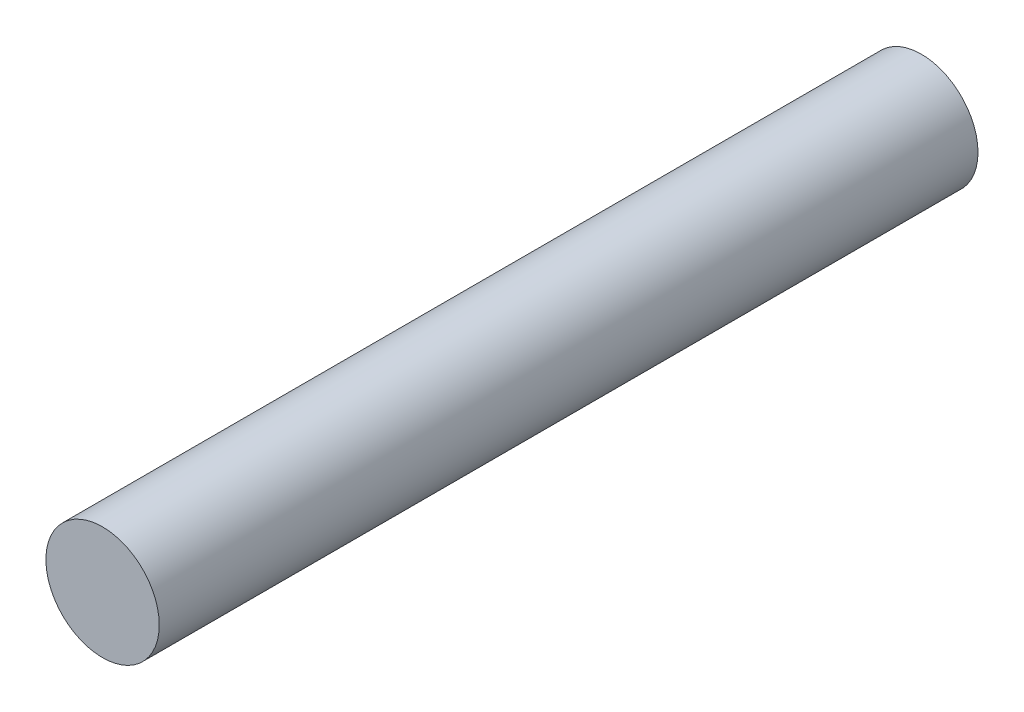
from build123d import *

# Parameters (mm, degrees)
SKETCH1_R           = 4.572
BOSS_EXTRUDE1_DEPTH = 66.04


with BuildPart() as part:
    # Sketch1 → Boss-Extrude1 (new body)
    with BuildSketch(Plane.XY):
        Circle(SKETCH1_R)
    extrude(amount=BOSS_EXTRUDE1_DEPTH)


solid = part.part
